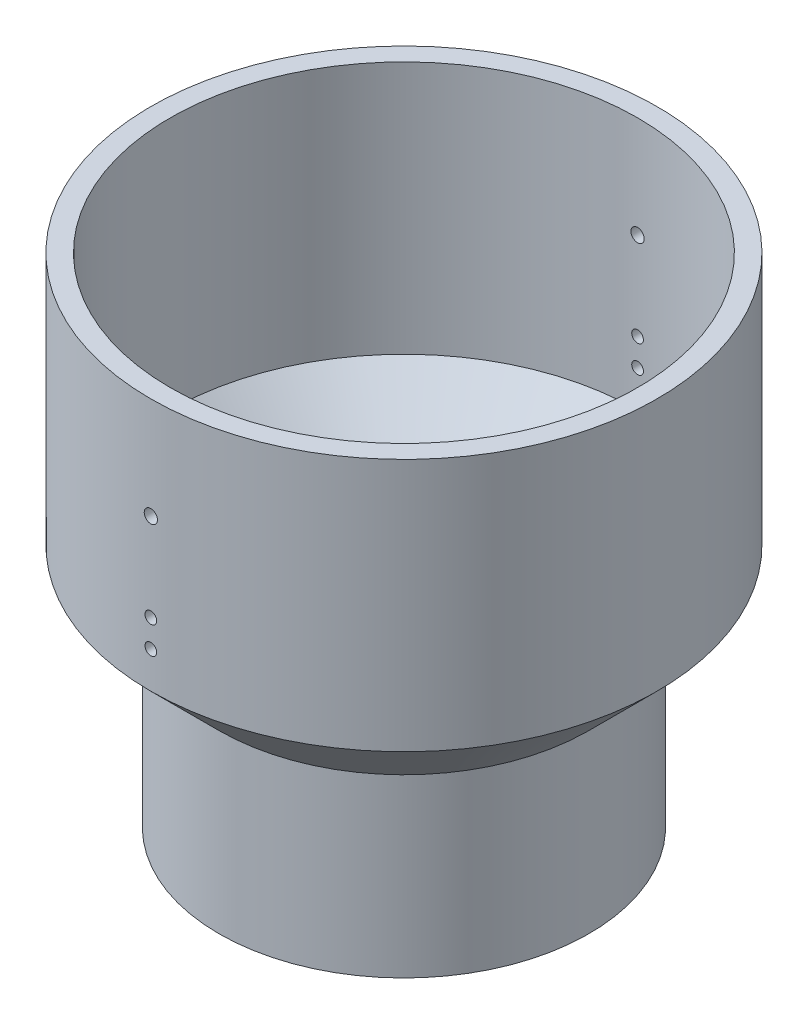
from build123d import *

# Parameters (mm, degrees)
SKETCH7_R          = 1.5
SKETCH7_R_2        = 1.7
CUT_EXTRUDE2_DEPTH = 131


with BuildPart() as part:
    # Sketch1 → Revolve1 (revolve)
    with BuildSketch(Plane.XY):
        Polygon((65, -65), (47.5, -82.5), (47.5, -127.679491924), (42.5, -127.679491924), (42.5, -82.5), (60, -65), (60, 0), (65, 0), align=None)
    revolve(axis=Axis((0, 0, 0), (0, -1, 0)))

    # Sketch7 → Cut-Extrude2 (cut, through all)
    with BuildSketch(Plane.XY.offset(-65)):
        with Locations((0, -48.62)):
            Circle(SKETCH7_R)
        with Locations((0, -55.62)):
            Circle(SKETCH7_R)
        with Locations((0, -26.08)):
            Circle(SKETCH7_R_2)
    extrude(amount=CUT_EXTRUDE2_DEPTH, mode=Mode.SUBTRACT)


solid = part.part
